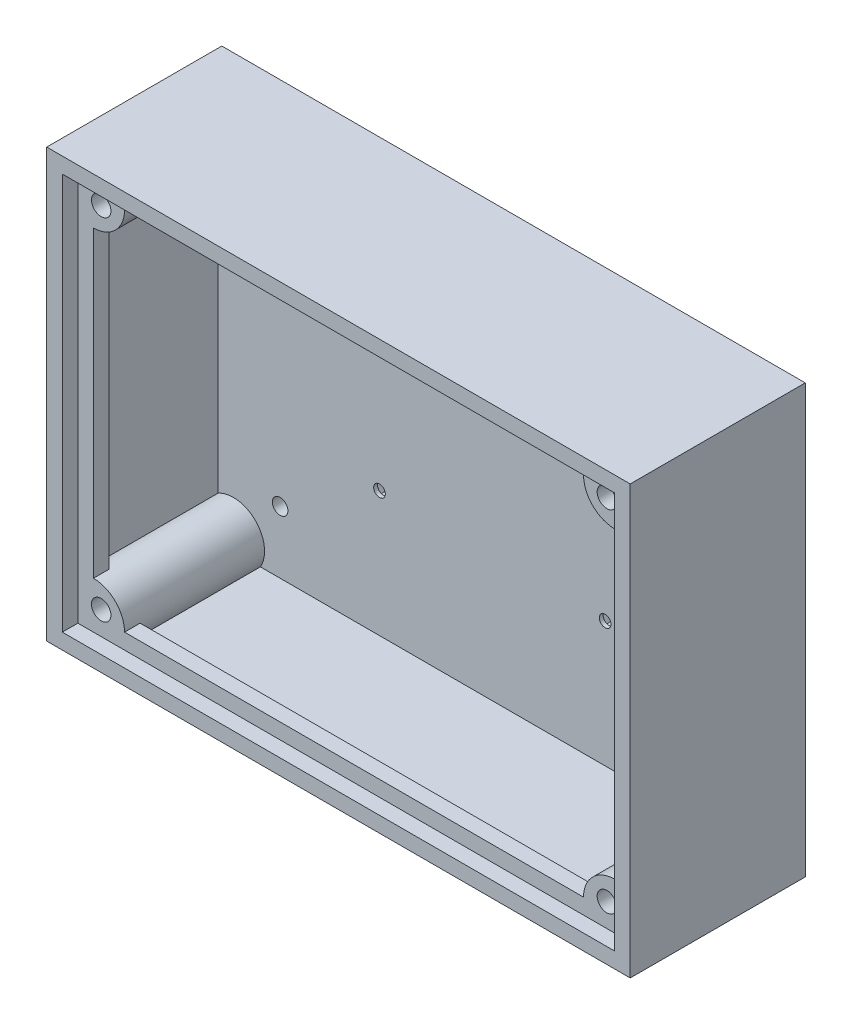
from build123d import *

# Parameters (mm, degrees)
SKETCH1_W           = 150
SKETCH1_H           = 110
BOSS_EXTRUDE1_DEPTH = 5
SKETCH4_W           = 150
SKETCH4_H           = 110
SKETCH4_W_2         = 142
SKETCH4_H_2         = 102
BOSS_EXTRUDE2_DEPTH = 40
CUT_EXTRUDE1_DEPTH  = 6
SKETCH5_W           = 142
SKETCH5_H           = 102
SKETCH5_W_2         = 134
SKETCH5_H_2         = 94
BOSS_EXTRUDE3_DEPTH = 8
SKETCH6_W           = 142
SKETCH6_H           = 102
SKETCH6_W_2         = 134
SKETCH6_H_2         = 94
CUT_EXTRUDE2_DEPTH  = 4
SKETCH7_R           = 8
BOSS_EXTRUDE4_DEPTH = 36
CUT_EXTRUDE3_DEPTH  = 36
CUT_EXTRUDE4_DEPTH  = 46
SKETCH10_R          = 1.5
BOSS_EXTRUDE5_DEPTH = 1


with BuildPart() as part:
    # Sketch1 → Boss-Extrude1 (new body)
    with BuildSketch(Plane.XY):
        with Locations((-27.181372549, -6.605392157)):
            Rectangle(SKETCH1_W, SKETCH1_H)
    extrude(amount=BOSS_EXTRUDE1_DEPTH)

    # Sketch4 → Boss-Extrude2 (add)
    with BuildSketch(Plane.XY.offset(5)):
        with Locations((-27.181372549, -6.605392157)):
            Rectangle(SKETCH4_W, SKETCH4_H)
        with Locations((-27.181372549, -6.605392157)):
            Rectangle(SKETCH4_W_2, SKETCH4_H_2, mode=Mode.SUBTRACT)
    extrude(amount=BOSS_EXTRUDE2_DEPTH)

    # Sketch2 → Cut-Extrude1 (cut, through all)
    with BuildSketch(Plane(origin=(0, 0, 5), x_dir=(-1, 0, 0), z_dir=(0, 0, 1))):
        Polygon((0.998328299, 25.346145297), (-0.185239753, 27.396145297), (-2.552375857, 27.396145297), (-3.735943908, 25.346145297), (-2.552375857, 23.296145297), (-0.185239753, 23.296145297), align=None)
        Polygon((55.447624143, 27.396145297), (54.264056092, 25.346145297), (55.447624143, 23.296145297), (57.814760247, 23.296145297), (58.998328299, 25.346145297), (57.814760247, 27.396145297), align=None)
        Polygon((-0.185239753, -21.603854703), (-2.552375857, -21.603854703), (-3.735943908, -23.653854703), (-2.552375857, -25.703854703), (-0.185239753, -25.703854703), (0.998328299, -23.653854703), align=None)
        Polygon((55.447624143, -21.603854703), (54.264056092, -23.653854703), (55.447624143, -25.703854703), (57.814760247, -25.703854703), (58.998328299, -23.653854703), (57.814760247, -21.603854703), align=None)
    extrude(amount=-CUT_EXTRUDE1_DEPTH, mode=Mode.SUBTRACT)

    # Sketch5 → Boss-Extrude3 (add)
    with BuildSketch(Plane.XY.offset(45)):
        with Locations((-27.181372549, -6.605392157)):
            Rectangle(SKETCH5_W, SKETCH5_H)
        with Locations((-27.181372549, -6.605392157)):
            Rectangle(SKETCH5_W_2, SKETCH5_H_2, mode=Mode.SUBTRACT)
    extrude(amount=-BOSS_EXTRUDE3_DEPTH)

    # Sketch6 → Cut-Extrude2 (cut)
    with BuildSketch(Plane.XY.offset(45)):
        with Locations((-27.181372549, -6.605392157)):
            Rectangle(SKETCH6_W, SKETCH6_H)
        with Locations((-27.181372549, -6.605392157)):
            Rectangle(SKETCH6_W_2, SKETCH6_H_2, mode=Mode.SUBTRACT)
    extrude(amount=-CUT_EXTRUDE2_DEPTH, mode=Mode.SUBTRACT)

    # Sketch7 → Boss-Extrude4 (add)
    with BuildSketch(Plane.XY.offset(41)):
        with Locations((-94.181372549, 40.394607843)):
            Circle(SKETCH7_R)
        with Locations((-94.181372549, -53.605392157)):
            Circle(SKETCH7_R)
        with Locations((39.818627451, -53.605392157)):
            Circle(SKETCH7_R)
        with Locations((39.818627451, 40.394607843)):
            Circle(SKETCH7_R)
    extrude(amount=-BOSS_EXTRUDE4_DEPTH)

    # Sketch8 → Cut-Extrude3 (cut)
    with BuildSketch(Plane.XY.offset(41)):
        with BuildLine():
            Line((-92.181372549, 35.894607843), (-92.181372549, 38.394607843))
            Line((-92.181372549, 38.394607843), (-89.681372549, 38.394607843))
            ThreePointArc((-89.681372549, 38.394607843), (-93.949139502, 40.162374796), (-92.181372549, 35.894607843))
        make_face()
        with BuildLine():
            Line((-89.681372549, 38.394607843), (-92.181372549, 38.394607843))
            Line((-92.181372549, 38.394607843), (-92.181372549, 35.894607843))
            ThreePointArc((-92.181372549, 35.894607843), (-90.413605596, 36.62684089), (-89.681372549, 38.394607843))
        make_face()
        with BuildLine():
            ThreePointArc((40.318627451, 38.394607843), (37.818627451, 40.894607843), (35.318627451, 38.394607843))
            Line((35.318627451, 38.394607843), (37.818627451, 38.394607843))
            Line((37.818627451, 38.394607843), (37.818627451, 35.894607843))
            ThreePointArc((37.818627451, 35.894607843), (39.586394404, 36.62684089), (40.318627451, 38.394607843))
        make_face()
        with BuildLine():
            Line((37.818627451, 38.394607843), (35.318627451, 38.394607843))
            ThreePointArc((35.318627451, 38.394607843), (36.050860498, 36.62684089), (37.818627451, 35.894607843))
            Line((37.818627451, 35.894607843), (37.818627451, 38.394607843))
        make_face()
        with BuildLine():
            ThreePointArc((40.318627451, -51.605392157), (39.586394404, -49.837625204), (37.818627451, -49.105392157))
            Line((37.818627451, -49.105392157), (37.818627451, -51.605392157))
            Line((37.818627451, -51.605392157), (35.318627451, -51.605392157))
            ThreePointArc((35.318627451, -51.605392157), (37.818627451, -54.105392157), (40.318627451, -51.605392157))
        make_face()
        with BuildLine():
            Line((37.818627451, -51.605392157), (37.818627451, -49.105392157))
            ThreePointArc((37.818627451, -49.105392157), (36.050860498, -49.837625204), (35.318627451, -51.605392157))
            Line((35.318627451, -51.605392157), (37.818627451, -51.605392157))
        make_face()
        with BuildLine():
            ThreePointArc((-89.681372549, -51.605392157), (-90.413605596, -49.837625204), (-92.181372549, -49.105392157))
            Line((-92.181372549, -49.105392157), (-92.181372549, -51.605392157))
            Line((-92.181372549, -51.605392157), (-89.681372549, -51.605392157))
        make_face()
        with BuildLine():
            Line((-92.181372549, -51.605392157), (-92.181372549, -49.105392157))
            ThreePointArc((-92.181372549, -49.105392157), (-93.949139502, -53.37315911), (-89.681372549, -51.605392157))
            Line((-89.681372549, -51.605392157), (-92.181372549, -51.605392157))
        make_face()
    extrude(amount=-CUT_EXTRUDE3_DEPTH, mode=Mode.SUBTRACT)

    # Sketch9 → Cut-Extrude4 (cut, through all)
    with BuildSketch(Plane(origin=(0, 0, 0), x_dir=(-1, 0, 0), z_dir=(0, 0, -1))):
        with BuildLine():
            Line((-27.818627451, 26.394607843), (-27.818627451, 28.394607843))
            Line((-27.818627451, 28.394607843), (-25.818627451, 28.394607843))
            ThreePointArc((-25.818627451, 28.394607843), (-29.232841013, 29.808821406), (-27.818627451, 26.394607843))
        make_face()
        with BuildLine():
            Line((-25.818627451, 28.394607843), (-27.818627451, 28.394607843))
            Line((-27.818627451, 28.394607843), (-27.818627451, 26.394607843))
            ThreePointArc((-27.818627451, 26.394607843), (-26.404413889, 26.980394281), (-25.818627451, 28.394607843))
        make_face()
        with BuildLine():
            ThreePointArc((-25.818627451, -41.605392157), (-26.404413889, -40.191178594), (-27.818627451, -39.605392157))
            Line((-27.818627451, -39.605392157), (-27.818627451, -41.605392157))
            Line((-27.818627451, -41.605392157), (-25.818627451, -41.605392157))
        make_face()
        with BuildLine():
            Line((-27.818627451, -41.605392157), (-27.818627451, -39.605392157))
            ThreePointArc((-27.818627451, -39.605392157), (-29.232841013, -43.019605719), (-25.818627451, -41.605392157))
            Line((-25.818627451, -41.605392157), (-27.818627451, -41.605392157))
        make_face()
        with BuildLine():
            ThreePointArc((84.181372549, -41.605392157), (83.595586111, -40.191178594), (82.181372549, -39.605392157))
            Line((82.181372549, -39.605392157), (82.181372549, -41.605392157))
            Line((82.181372549, -41.605392157), (80.181372549, -41.605392157))
            ThreePointArc((80.181372549, -41.605392157), (82.181372549, -43.605392157), (84.181372549, -41.605392157))
        make_face()
        with BuildLine():
            Line((82.181372549, -41.605392157), (82.181372549, -39.605392157))
            ThreePointArc((82.181372549, -39.605392157), (80.767158987, -40.191178594), (80.181372549, -41.605392157))
            Line((80.181372549, -41.605392157), (82.181372549, -41.605392157))
        make_face()
        with BuildLine():
            ThreePointArc((84.181372549, 28.394607843), (82.181372549, 30.394607843), (80.181372549, 28.394607843))
            Line((80.181372549, 28.394607843), (82.181372549, 28.394607843))
            Line((82.181372549, 28.394607843), (82.181372549, 26.394607843))
            ThreePointArc((82.181372549, 26.394607843), (83.595586111, 26.980394281), (84.181372549, 28.394607843))
        make_face()
        with BuildLine():
            Line((82.181372549, 28.394607843), (80.181372549, 28.394607843))
            ThreePointArc((80.181372549, 28.394607843), (80.767158987, 26.980394281), (82.181372549, 26.394607843))
            Line((82.181372549, 26.394607843), (82.181372549, 28.394607843))
        make_face()
    extrude(amount=-CUT_EXTRUDE4_DEPTH, mode=Mode.SUBTRACT)

    # Sketch10 → Boss-Extrude5 (add)
    with BuildSketch(Plane.XY.offset(5)):
        with BuildLine():
            ThreePointArc((-0.131192195, 23.653854703), (1.368807805, 25.153854703), (2.868807805, 23.653854703))
            Line((2.868807805, 23.653854703), (3.735943908, 23.653854703))
            Line((3.735943908, 23.653854703), (2.552375857, 25.703854703))
            Line((2.552375857, 25.703854703), (0.185239753, 25.703854703))
            Line((0.185239753, 25.703854703), (-0.998328299, 23.653854703))
            Line((-0.998328299, 23.653854703), (-0.131192195, 23.653854703))
        make_face()
        Polygon((-54.264056092, 23.653854703), (-55.447624143, 25.703854703), (-57.814760247, 25.703854703), (-58.998328299, 23.653854703), (-57.814760247, 21.603854703), (-55.447624143, 21.603854703), align=None)
        with Locations((-56.631192195, 23.653854703)):
            Circle(SKETCH10_R, mode=Mode.SUBTRACT)
        Polygon((-54.264056092, -25.346145297), (-55.447624143, -23.296145297), (-57.814760247, -23.296145297), (-58.998328299, -25.346145297), (-57.814760247, -27.396145297), (-55.447624143, -27.396145297), align=None)
        with Locations((-56.631192195, -25.346145297)):
            Circle(SKETCH10_R, mode=Mode.SUBTRACT)
        Polygon((3.735943908, -25.346145297), (2.552375857, -23.296145297), (0.185239753, -23.296145297), (-0.998328299, -25.346145297), (0.185239753, -27.396145297), (2.552375857, -27.396145297), align=None)
        with Locations((1.368807805, -25.346145297)):
            Circle(SKETCH10_R, mode=Mode.SUBTRACT)
    extrude(amount=-BOSS_EXTRUDE5_DEPTH)


solid = part.part
